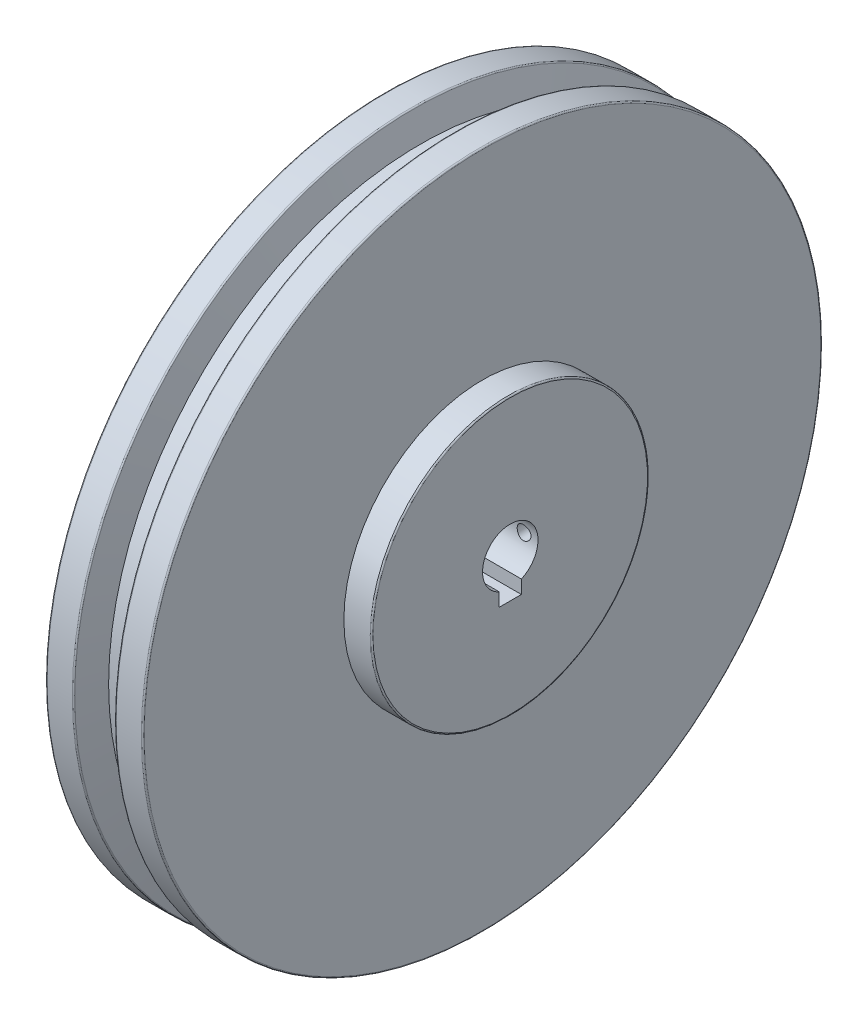
from build123d import *

# Parameters (mm, degrees)
ESBO_O1_W             = 8
ESBO_O1_H             = 8
CORTE_EXTRUS_O1_DEPTH = 46
ESBO_O3_R             = 2.5
CORTE_EXTRUS_O2_DEPTH = 123.5


with BuildPart() as part:
    # Sketch1 → Revolve1 (revolve)
    with BuildSketch(Plane.XY):
        with BuildLine():
            Line((0, -20), (0, -122))
            ThreePointArc((0, -122), (0.146446609, -122.353553391), (0.5, -122.5))
            Line((0.5, -122.5), (9.616336506, -122.5))
            ThreePointArc((9.616336506, -122.5), (9.920717221, -122.39667667), (10.099299419, -122.129409523))
            Line((10.099299419, -122.129409523), (12.679491924, -112.5))
            Line((12.679491924, -112.5), (22.320508076, -112.5))
            Line((22.320508076, -112.5), (24.900700581, -122.129409523))
            ThreePointArc((24.900700581, -122.129409523), (25.079282779, -122.39667667), (25.383663494, -122.5))
            Line((25.383663494, -122.5), (34.5, -122.5))
            ThreePointArc((34.5, -122.5), (34.853553391, -122.353553391), (35, -122))
            Line((35, -122), (35, -50))
            Line((35, -50), (44.5, -50))
            ThreePointArc((44.5, -50), (44.853553391, -49.853553391), (45, -49.5))
            Line((45, -49.5), (45, -10))
            Line((45, -10), (2.5, -10))
            Line((2.5, -10), (0, -20))
        make_face()
    revolve(axis=Axis((0, 0, 0), (1, 0, 0)))

    # Esboço1 → Corte-extrusão1 (cut, through all)
    with BuildSketch(Plane.ZY):
        with Locations((0, -10)):
            Rectangle(ESBO_O1_W, ESBO_O1_H)
    extrude(amount=-CORTE_EXTRUS_O1_DEPTH, mode=Mode.SUBTRACT)

    # Esboço3 → Corte-extrusão2 (cut, through all)
    with BuildSketch(Plane.XY):
        with Locations((40, 0)):
            Circle(ESBO_O3_R)
    extrude(amount=-CORTE_EXTRUS_O2_DEPTH, mode=Mode.SUBTRACT)


solid = part.part
